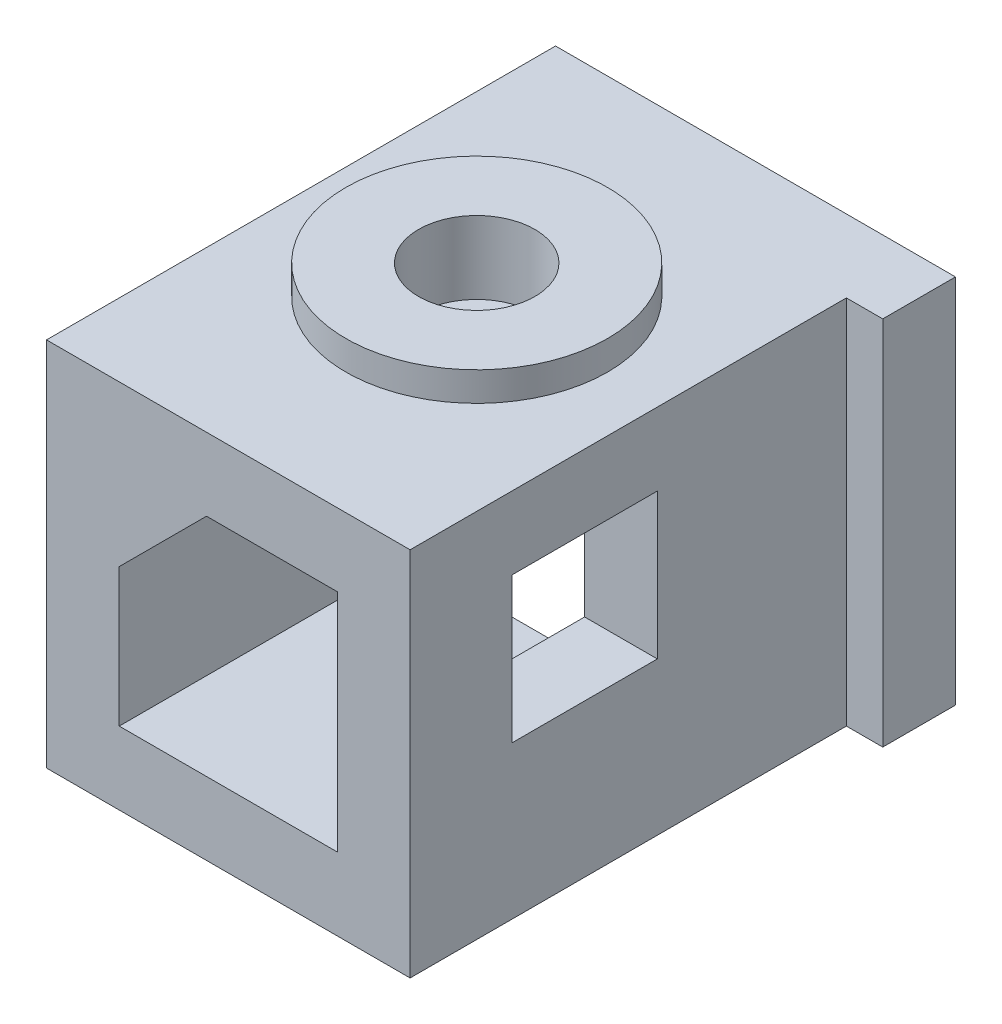
from build123d import *

# Parameters (mm, degrees)
BOSS_EXTRUDE1_DEPTH = 35
SKETCH2_R           = 9
BOSS_EXTRUDE2_DEPTH = 2
SKETCH3_R           = 4
CUT_EXTRUDE1_DEPTH  = 5
SKETCH4_W           = 5
SKETCH4_H           = 35
BOSS_EXTRUDE3_DEPTH = 20.5
SKETCH6_W           = 5
SKETCH6_H           = 25.5
BOSS_EXTRUDE4_DEPTH = 2.5
SKETCH7_W           = 5
SKETCH7_H           = 20
BOSS_EXTRUDE5_DEPTH = 7.5
SKETCH8_W           = 20
SKETCH8_H           = 5
BOSS_EXTRUDE6_DEPTH = 15
SKETCH10_W          = 10
SKETCH10_H          = 10
CUT_EXTRUDE2_DEPTH  = 5


with BuildPart() as part:
    # Sketch1 → Boss-Extrude1 (new body)
    with BuildSketch(Plane.XY):
        Polygon((-9.305574102, 4.73561153), (15.694425898, 4.73561153), (15.694425898, -0.26438847), (1.694425898, -0.26438847), (-4.305574102, -6.26438847), (-4.305574102, -13.26438847), (-9.305574102, -13.26438847), align=None)
    extrude(amount=BOSS_EXTRUDE1_DEPTH)

    # Sketch2 → Boss-Extrude2 (add)
    with BuildSketch(Plane(origin=(0, 4.73561153, 0), x_dir=(1, 0, 0), z_dir=(0, 1, 0))):
        with Locations((2.904425898, -17.63)):
            Circle(SKETCH2_R)
    extrude(amount=BOSS_EXTRUDE2_DEPTH)

    # Sketch3 → Cut-Extrude1 (cut)
    with BuildSketch(Plane(origin=(0, 6.73561153, 0), x_dir=(1, 0, 0), z_dir=(0, 1, 0))):
        with Locations((2.904425898, -17.63)):
            Circle(SKETCH3_R)
    extrude(amount=-CUT_EXTRUDE1_DEPTH, mode=Mode.SUBTRACT)

    # Sketch4 → Boss-Extrude3 (add)
    with BuildSketch(Plane.XZ.offset(0.26438847)):
        with Locations((13.194425898, 17.5)):
            Rectangle(SKETCH4_W, SKETCH4_H)
    extrude(amount=BOSS_EXTRUDE3_DEPTH)

    # Sketch6 → Boss-Extrude4 (add)
    with BuildSketch(Plane(origin=(15.694425898, 0, 0), x_dir=(0, 0, -1), z_dir=(1, 0, 0))):
        with Locations((-2.5, -8.01438847)):
            Rectangle(SKETCH6_W, SKETCH6_H)
    extrude(amount=BOSS_EXTRUDE4_DEPTH)

    # Sketch7 → Boss-Extrude5 (add)
    with BuildSketch(Plane.XZ.offset(13.26438847)):
        with Locations((-6.805574102, 25)):
            Rectangle(SKETCH7_W, SKETCH7_H)
    extrude(amount=BOSS_EXTRUDE5_DEPTH)

    # Sketch8 → Boss-Extrude6 (add)
    with BuildSketch(Plane(origin=(-4.305574102, 0, 0), x_dir=(0, 0, -1), z_dir=(1, 0, 0))):
        with Locations((-25, -18.26438847)):
            Rectangle(SKETCH8_W, SKETCH8_H)
    extrude(amount=BOSS_EXTRUDE6_DEPTH)

    # Sketch10 → Cut-Extrude2 (cut)
    with BuildSketch(Plane(origin=(15.694425898, 0, 0), x_dir=(0, 0, -1), z_dir=(1, 0, 0))):
        with Locations((-23, -5.26438847)):
            Rectangle(SKETCH10_W, SKETCH10_H)
    extrude(amount=-CUT_EXTRUDE2_DEPTH, mode=Mode.SUBTRACT)


solid = part.part
